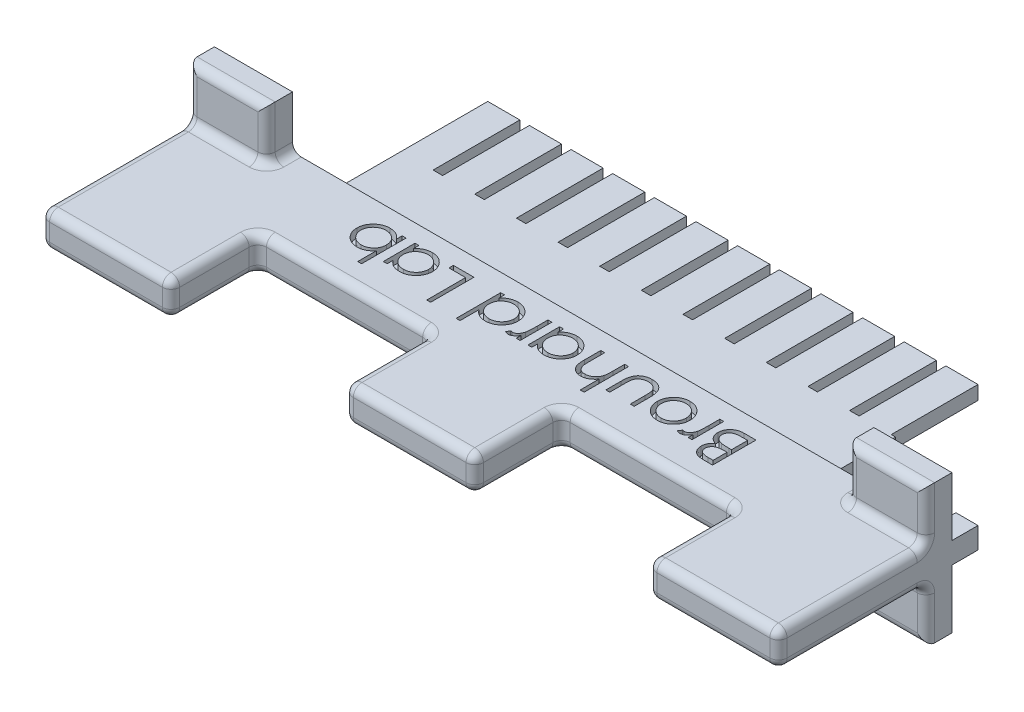
from build123d import *

# Parameters (mm, degrees)
SKETCH1_W           = 85
SKETCH1_H           = 4
BOSS_EXTRUDE1_DEPTH = 10
SKETCH2_W           = 15
SKETCH2_H           = 4
BOSS_EXTRUDE2_DEPTH = 10
SKETCH3_W           = 2.55
SKETCH3_H           = 2.45
BOSS_EXTRUDE3_DEPTH = 3
SKETCH4_W           = 57
SKETCH4_H           = 1.6
BOSS_EXTRUDE4_DEPTH = 7.5
SKETCH6_W           = 9
SKETCH6_H           = 6
BOSS_EXTRUDE6_DEPTH = 3
FILLET1_R           = 1
CUT_EXTRUDE1_DEPTH  = 1
SKETCH5_W           = 3.7
SKETCH5_H           = 1.6
BOSS_EXTRUDE5_DEPTH = 10


with BuildPart() as part:
    # Sketch1 → Boss-Extrude1 (new body)
    with BuildSketch(Plane.XY):
        Rectangle(SKETCH1_W, SKETCH1_H)
    extrude(amount=BOSS_EXTRUDE1_DEPTH)

    # Sketch2 → Boss-Extrude2 (add)
    with BuildSketch(Plane.XY.offset(10)):
        with Locations((-35, 0)):
            Rectangle(SKETCH2_W, SKETCH2_H)
        with Locations((35, 0)):
            Rectangle(SKETCH2_W, SKETCH2_H)
        Rectangle(SKETCH2_W, SKETCH2_H)
    extrude(amount=BOSS_EXTRUDE2_DEPTH)

    # Sketch3 → Boss-Extrude3 (add)
    with BuildSketch(Plane(origin=(0, 0, 0), x_dir=(-1, 0, 0), z_dir=(0, 0, -1))):
        with Locations((-41.225, 0)):
            Rectangle(SKETCH3_W, SKETCH3_H)
        with Locations((41.225, 0)):
            Rectangle(SKETCH3_W, SKETCH3_H)
    extrude(amount=BOSS_EXTRUDE3_DEPTH)

    # Sketch4 → Boss-Extrude4 (add)
    with BuildSketch(Plane(origin=(0, 0, 0), x_dir=(-1, 0, 0), z_dir=(0, 0, -1))):
        Rectangle(SKETCH4_W, SKETCH4_H)
    extrude(amount=BOSS_EXTRUDE4_DEPTH)

    # Sketch6 → Boss-Extrude6 (add)
    with BuildSketch(Plane(origin=(0, 0, 0), x_dir=(-1, 0, 0), z_dir=(0, 0, -1))):
        with Locations((38, -5)):
            Rectangle(SKETCH6_W, SKETCH6_H)
        with Locations((38, 5)):
            Rectangle(SKETCH6_W, SKETCH6_H)
        with Locations((-38, -5)):
            Rectangle(SKETCH6_W, SKETCH6_H)
        with Locations((-38, 5)):
            Rectangle(SKETCH6_W, SKETCH6_H)
    extrude(amount=-BOSS_EXTRUDE6_DEPTH)

    # Fillet1
    fillet1_edges = [part.edges().sort_by_distance(p)[0] for p in [
        (-42.5, 5, 3),
        (-38, 2, 3),
        (-33.5, 5, 3),
        (-33.5, 2, 1.5),
        (-38, 8, 3),
        (42.5, -5, 3),
        (38, -2, 3),
        (33.5, -5, 3),
        (33.5, -2, 1.5),
        (38, -8, 3),
        (42.5, 5, 3),
        (38, 8, 3),
        (33.5, 5, 3),
        (38, 2, 3),
        (33.5, 2, 1.5),
        (-17.5, -2, 10),
        (-27.5, 0, 10),
        (-27.5, -2, 15),
        (-27.5, 2, 15),
        (-42.5, 0, 20),
        (-35, -2, 20),
        (-27.5, 0, 20),
        (-35, 2, 20),
        (17.5, 2, 10),
        (27.5, 0, 10),
        (27.5, 2, 15),
        (27.5, -2, 15),
        (42.5, 0, 20),
        (35, 2, 20),
        (27.5, 0, 20),
        (35, -2, 20),
        (17.5, -2, 10),
        (-17.5, 2, 10),
        (7.5, 0, 10),
        (7.5, -2, 15),
        (7.5, 2, 15),
        (-7.5, 0, 10),
        (-7.5, 2, 15),
        (-7.5, -2, 15),
        (7.5, 0, 20),
        (0, 2, 20),
        (-7.5, 0, 20),
        (0, -2, 20),
        (42.5, -2, 11.5),
        (-42.5, -2, 11.5),
        (-42.5, 2, 11.5),
        (42.5, 2, 11.5),
        (-42.5, -5, 3),
        (-38, -8, 3),
        (-33.5, -5, 3),
        (-38, -2, 3),
        (-33.5, -2, 1.5),
    ]]
    fillet(fillet1_edges, radius=FILLET1_R)

    # Sketch8 → Cut-Extrude1 (cut)
    with BuildSketch(Plane(origin=(0, 2, 0), x_dir=(1, 0, 0), z_dir=(0, 1, 0))):
        with BuildLine():
            Line((21.955128205, -7.045024133), (20.979567308, -7.045024133))
            add(Edge.make_bspline(
                [(20.979567308, -7.045024133), (20.931811586, -7.044777014), (20.839249111, -7.044298035), (20.704660144, -7.036696988), (20.578554958, -7.026592114), (20.461156398, -7.009641733), (20.351700568, -6.992066423), (20.251298675, -6.966270076), (20.159109728, -6.937777071), (20.048409672, -6.893936716), (19.92280529, -6.825852091), (19.787804083, -6.724876123), (19.670452795, -6.603814091), (19.570669416, -6.465854357), (19.490591132, -6.314083016), (19.43339094, -6.151765477), (19.396643358, -5.981632539), (19.392911608, -5.864990679), (19.391025641, -5.806041761)],
                knots=[0, 0, 0, 0, 0.000143243, 0.000277641, 0.000404323, 0.000522601, 0.000633422, 0.000736665, 0.000833282, 0.000922745, 0.001093491, 0.001260157, 0.001426607, 0.001597303, 0.001769346, 0.001939468, 0.002112331, 0.002288957, 0.002288957, 0.002288957, 0.002288957], degree=3))
            add(Edge.make_bspline(
                [(19.391025641, -5.806041761), (19.392566125, -5.750816773), (19.395593321, -5.642294463), (19.425166581, -5.484100137), (19.4698067, -5.333038737), (19.534225102, -5.190566035), (19.616363978, -5.057933935), (19.716298264, -4.937404803), (19.834792937, -4.831345021), (19.923759393, -4.772321243), (19.968950321, -4.742339838)],
                knots=[0, 0, 0, 0, 0.00016551, 0.000325243, 0.000481139, 0.000637145, 0.000792791, 0.000947835, 0.001105294, 0.001267844, 0.001267844, 0.001267844, 0.001267844], degree=3))
            add(Edge.make_bspline(
                [(19.968950321, -4.742339838), (19.912145679, -4.720542475), (19.803464327, -4.678838718), (19.653711211, -4.604821394), (19.524645211, -4.524933301), (19.41460302, -4.438588883), (19.32239544, -4.34296875), (19.240253224, -4.240591123), (19.170541651, -4.127890536), (19.111062126, -4.007309158), (19.063944891, -3.879485542), (19.031238978, -3.745375962), (19.010496783, -3.606499394), (19.007784363, -3.512111636), (19.006410256, -3.464294967)],
                knots=[0, 0, 0, 0, 0.000182459, 0.00034909, 0.000500276, 0.000637148, 0.000767471, 0.00089793, 0.001030217, 0.001164151, 0.001300726, 0.001437979, 0.001577644, 0.001721044, 0.001721044, 0.001721044, 0.001721044], degree=3))
            add(Edge.make_bspline(
                [(19.006410256, -3.464294967), (19.007805885, -3.41548523), (19.010551822, -3.319450707), (19.030807012, -3.178370784), (19.065112767, -3.043553694), (19.112331393, -2.914102037), (19.173883248, -2.790773975), (19.248244287, -2.672600284), (19.337493216, -2.561332318), (19.437996289, -2.45535544), (19.550128803, -2.358444164), (19.673690061, -2.2751618), (19.805513315, -2.203227398), (19.947403728, -2.145396174), (20.098354491, -2.100124903), (20.258400966, -2.068824422), (20.427452272, -2.047649449), (20.543467886, -2.045914087), (20.602964744, -2.045024133)],
                knots=[0, 0, 0, 0, 0.000146402, 0.00028805, 0.000426518, 0.000563092, 0.000700608, 0.000839267, 0.000981145, 0.001127794, 0.001276955, 0.001424748, 0.00157399, 0.001726698, 0.001883553, 0.002046002, 0.002215459, 0.002393845, 0.002393845, 0.002393845, 0.002393845], degree=3))
            Line((20.602964744, -2.045024133), (21.955128205, -2.045024133))
            Line((21.955128205, -2.045024133), (21.955128205, -7.045024133))
        make_face()
        with BuildLine():
            Line((21.506410256, -6.53220362), (21.506410256, -4.929639518))
            Line((21.506410256, -4.929639518), (21.204927885, -4.929639518))
            add(Edge.make_bspline(
                [(21.204927885, -4.929639518), (21.16085778, -4.930206082), (21.075705357, -4.9313008), (20.952063514, -4.934535484), (20.837581625, -4.943196106), (20.731865233, -4.952356158), (20.635622811, -4.966460704), (20.548532434, -4.983720889), (20.469810894, -5.00181496), (20.379071632, -5.032675643), (20.276157749, -5.077807077), (20.16721677, -5.149562501), (20.069164992, -5.232639769), (19.988277934, -5.331182392), (19.920936523, -5.437599512), (19.875598165, -5.552684686), (19.843986577, -5.672472047), (19.841172407, -5.755083607), (19.83974359, -5.797027338)],
                knots=[0, 0, 0, 0, 0.000132227, 0.000255489, 0.000370952, 0.000476596, 0.000573767, 0.000662554, 0.000742964, 0.000815812, 0.000949851, 0.001078759, 0.001205868, 0.001333854, 0.001459773, 0.001581973, 0.001703679, 0.001829203, 0.001829203, 0.001829203, 0.001829203], degree=3))
            add(Edge.make_bspline(
                [(19.83974359, -5.797027338), (19.840440447, -5.824795004), (19.841807408, -5.879264312), (19.85469429, -5.958622966), (19.872478035, -6.034141042), (19.901807859, -6.103782707), (19.936556119, -6.169993364), (19.98109509, -6.230681546), (20.03245262, -6.287491301), (20.092329064, -6.338899898), (20.160479658, -6.385396007), (20.239063252, -6.424101797), (20.325943351, -6.458499162), (20.422931675, -6.48457317), (20.528096305, -6.507209559), (20.643041681, -6.521483941), (20.767075062, -6.530654029), (20.853013063, -6.531675569), (20.897435897, -6.53220362)],
                knots=[0, 0, 0, 0, 8.3229e-05, 0.000163264, 0.000240757, 0.000315341, 0.000389283, 0.000464617, 0.000540481, 0.000618594, 0.000700823, 0.000787274, 0.000880832, 0.000980716, 0.001088168, 0.001203335, 0.00132786, 0.001461107, 0.001461107, 0.001461107, 0.001461107], degree=3))
            Line((20.897435897, -6.53220362), (21.506410256, -6.53220362))
        make_face(mode=Mode.SUBTRACT)
        with BuildLine():
            Line((21.506410256, -4.416819005), (21.506410256, -2.557844646))
            Line((21.506410256, -2.557844646), (20.867387821, -2.557844646))
            add(Edge.make_bspline(
                [(20.867387821, -2.557844646), (20.82165107, -2.558445571), (20.733499514, -2.559603775), (20.606126985, -2.562352033), (20.48869926, -2.57254806), (20.380238634, -2.582323383), (20.281246941, -2.598293401), (20.190761319, -2.61375789), (20.110848501, -2.63651465), (20.017345889, -2.667828353), (19.912764158, -2.717871803), (19.798555972, -2.791464981), (19.697962318, -2.881106895), (19.612615651, -2.984324471), (19.541653639, -3.095395221), (19.492561941, -3.214537751), (19.460753316, -3.337772506), (19.457007017, -3.422035912), (19.455128205, -3.464294967)],
                knots=[0, 0, 0, 0, 0.000137234, 0.000264501, 0.000382034, 0.000490767, 0.000591058, 0.000682796, 0.000765899, 0.000840017, 0.000978463, 0.001112367, 0.001246451, 0.001380849, 0.001513136, 0.001640186, 0.001766022, 0.001892621, 0.001892621, 0.001892621, 0.001892621], degree=3))
            add(Edge.make_bspline(
                [(19.455128205, -3.464294967), (19.455511728, -3.490717987), (19.456272588, -3.543137822), (19.468232548, -3.620102651), (19.484829912, -3.695025725), (19.509289766, -3.766889341), (19.538879538, -3.836930979), (19.577915987, -3.902871611), (19.621948812, -3.967518228), (19.690148998, -4.050208407), (19.790699472, -4.144331407), (19.933635519, -4.235332182), (20.095250073, -4.309910154), (20.212743455, -4.341437989), (20.2734375, -4.357724454)],
                knots=[0, 0, 0, 0, 7.9184e-05, 0.00015709, 0.000233139, 0.000309156, 0.000384516, 0.000460796, 0.000538586, 0.000618995, 0.000781989, 0.000949233, 0.001125381, 0.001313608, 0.001313608, 0.001313608, 0.001313608], degree=3))
            add(Edge.make_bspline(
                [(20.2734375, -4.357724454), (20.297764757, -4.36266062), (20.350511268, -4.373363246), (20.436522534, -4.384653585), (20.535045896, -4.394781387), (20.645660247, -4.402076233), (20.768805516, -4.409907124), (20.904442139, -4.412844185), (21.052666008, -4.416429024), (21.15551238, -4.416685686), (21.208934295, -4.416819005)],
                knots=[0, 0, 0, 0, 7.4449e-05, 0.000161422, 0.000260089, 0.000371555, 0.000493951, 0.000630228, 0.000778496, 0.000938755, 0.000938755, 0.000938755, 0.000938755], degree=3))
            Line((21.208934295, -4.416819005), (21.506410256, -4.416819005))
        make_face(mode=Mode.SUBTRACT)
        with BuildLine():
            Line((18.237179487, -5.698870287), (17.788461538, -5.698870287))
            Line((17.788461538, -5.698870287), (17.788461538, -5.16100971))
            add(Edge.make_bspline(
                [(17.788461538, -5.16100971), (17.755359908, -5.211117117), (17.692053298, -5.306947144), (17.586273377, -5.43343718), (17.479111393, -5.53983342), (17.366921794, -5.622588498), (17.252557594, -5.685650706), (17.136357118, -5.730343447), (17.017481778, -5.757585182), (16.937237879, -5.761174556), (16.897035256, -5.762972851)],
                knots=[0, 0, 0, 0, 0.000180032, 0.00034431, 0.000493764, 0.000631989, 0.000761087, 0.000884414, 0.00100446, 0.00112499, 0.00112499, 0.00112499, 0.00112499], degree=3))
            add(Edge.make_bspline(
                [(16.897035256, -5.762972851), (16.865844687, -5.761310147), (16.801992924, -5.757906343), (16.705041331, -5.732794344), (16.604739598, -5.694222955), (16.540012887, -5.657063647), (16.506410256, -5.637772531)],
                knots=[0, 0, 0, 0, 9.3493e-05, 0.000191394, 0.000298902, 0.000414971, 0.000414971, 0.000414971, 0.000414971], degree=3))
            Line((16.506410256, -5.637772531), (16.752804487, -5.249150736))
            add(Edge.make_bspline(
                [(16.752804487, -5.249150736), (16.774388803, -5.258779687), (16.815359967, -5.277057281), (16.875295061, -5.298688724), (16.930554114, -5.311425747), (16.965759197, -5.313355343), (16.982171474, -5.314254902)],
                knots=[0, 0, 0, 0, 7.0888e-05, 0.000134558, 0.000190943, 0.000240184, 0.000240184, 0.000240184, 0.000240184], degree=3))
            add(Edge.make_bspline(
                [(16.982171474, -5.314254902), (17.018552318, -5.311962095), (17.092095887, -5.307327204), (17.199553418, -5.267726819), (17.305221395, -5.20820996), (17.387285817, -5.138004944), (17.451536641, -5.071852679), (17.497773588, -5.013639038), (17.539299542, -4.947803919), (17.579572406, -4.876841023), (17.616991286, -4.798984205), (17.65042989, -4.714102186), (17.681701622, -4.622897124), (17.699312387, -4.559480067), (17.708333333, -4.526995287)],
                knots=[0, 0, 0, 0, 0.000108839, 0.000220017, 0.000339778, 0.000471355, 0.000542193, 0.000616339, 0.000693851, 0.000775474, 0.000861039, 0.000952734, 0.001049023, 0.001150145, 0.001150145, 0.001150145, 0.001150145], degree=3))
            add(Edge.make_bspline(
                [(17.708333333, -4.526995287), (17.715105579, -4.4980295), (17.73018081, -4.433550753), (17.744447085, -4.325868753), (17.75911049, -4.198727857), (17.769124119, -4.051980366), (17.778583328, -3.885062178), (17.783808984, -3.698693379), (17.788295276, -3.492361731), (17.78840435, -3.348446216), (17.788461538, -3.272988877)],
                knots=[0, 0, 0, 0, 8.9193e-05, 0.000198547, 0.000325526, 0.000473173, 0.000639683, 0.000827079, 0.001032447, 0.001258811, 0.001258811, 0.001258811, 0.001258811], degree=3))
            Line((17.788461538, -3.272988877), (17.788461538, -2.045024133))
            Line((17.788461538, -2.045024133), (18.237179487, -2.045024133))
            Line((18.237179487, -2.045024133), (18.237179487, -5.698870287))
        make_face()
        with BuildLine():
            add(Edge.make_bspline(
                [(14.29286859, -5.762972851), (14.224307927, -5.761517291), (14.089877222, -5.758663293), (13.893032913, -5.728009819), (13.705327588, -5.681525783), (13.525956048, -5.616093456), (13.356402056, -5.530243686), (13.195151776, -5.426425769), (13.042528278, -5.303937317), (12.951070622, -5.209132095), (12.904647436, -5.16100971)],
                knots=[0, 0, 0, 0, 0.000205526, 0.000402987, 0.000596112, 0.000784972, 0.000974447, 0.001165038, 0.001359476, 0.001559909, 0.001559909, 0.001559909, 0.001559909], degree=3))
            add(Edge.make_bspline(
                [(12.904647436, -5.16100971), (12.864673216, -5.11498973), (12.785498387, -5.023840384), (12.683975931, -4.876046652), (12.59651656, -4.722989365), (12.526426616, -4.562636041), (12.471162296, -4.396386511), (12.431925587, -4.223669352), (12.408587109, -4.044865999), (12.405440013, -3.923431945), (12.403846154, -3.861931185)],
                knots=[0, 0, 0, 0, 0.000182745, 0.000361954, 0.000536876, 0.000710881, 0.000886036, 0.001061708, 0.001241475, 0.001425944, 0.001425944, 0.001425944, 0.001425944], degree=3))
            add(Edge.make_bspline(
                [(12.403846154, -3.861931185), (12.405248064, -3.800073959), (12.408018305, -3.677841197), (12.434223472, -3.497813533), (12.474982163, -3.323249495), (12.533313369, -3.154879952), (12.608110636, -2.992190127), (12.699383171, -2.835891045), (12.807770716, -2.685672654), (12.930635425, -2.542816985), (13.066416897, -2.411135675), (13.21375075, -2.296436369), (13.369848434, -2.197755629), (13.536840837, -2.119375683), (13.712350874, -2.056195988), (13.8974949, -2.012629522), (14.09210775, -1.986052796), (14.225006973, -1.982656037), (14.29286859, -1.980921569)],
                knots=[0, 0, 0, 0, 0.00018547, 0.000366497, 0.000544574, 0.000722589, 0.000900065, 0.001080956, 0.001264689, 0.001455025, 0.001645575, 0.001831106, 0.002014249, 0.002198383, 0.002383395, 0.002572886, 0.002767942, 0.002971467, 0.002971467, 0.002971467, 0.002971467], degree=3))
            add(Edge.make_bspline(
                [(14.29286859, -1.980921569), (14.361059424, -1.982670388), (14.494614618, -1.986095539), (14.689960267, -2.012431829), (14.875883807, -2.056661478), (15.052224048, -2.118593533), (15.219215773, -2.198399418), (15.37588985, -2.296052412), (15.523293198, -2.411193757), (15.65911724, -2.542801247), (15.781970535, -2.685676709), (15.890361026, -2.835889993), (15.981632796, -2.992190401), (16.056430263, -3.154879879), (16.114761415, -3.323249515), (16.155520121, -3.497813528), (16.181725284, -3.677841198), (16.184495525, -3.80007396), (16.185897436, -3.861931185)],
                knots=[0, 0, 0, 0, 0.000204526, 0.000400574, 0.000590065, 0.000776965, 0.000960195, 0.001144188, 0.00132972, 0.001520269, 0.001710605, 0.001894339, 0.00207523, 0.002252706, 0.002430721, 0.002608798, 0.002789825, 0.002975294, 0.002975294, 0.002975294, 0.002975294], degree=3))
            add(Edge.make_bspline(
                [(16.185897436, -3.861931185), (16.184296519, -3.923099043), (16.18112698, -4.044200892), (16.157756652, -4.22264832), (16.118946868, -4.394836864), (16.062916427, -4.560178538), (15.992956591, -4.720146456), (15.90637746, -4.873764934), (15.803872945, -5.02091287), (15.725005709, -5.111941341), (15.685096154, -5.158004902)],
                knots=[0, 0, 0, 0, 0.000183468, 0.000363236, 0.000538908, 0.000712162, 0.000886167, 0.001061962, 0.001240348, 0.001423094, 0.001423094, 0.001423094, 0.001423094], degree=3))
            add(Edge.make_bspline(
                [(15.685096154, -5.158004902), (15.638739114, -5.20653651), (15.547569839, -5.301982456), (15.394241809, -5.424229232), (15.233685171, -5.529446865), (15.063037498, -5.615253429), (14.883167202, -5.681407061), (14.694066814, -5.728226774), (14.496506031, -5.758527704), (14.361424213, -5.761476369), (14.29286859, -5.762972851)],
                knots=[0, 0, 0, 0, 0.00020114, 0.000395577, 0.000586713, 0.000776188, 0.000967274, 0.001160399, 0.001359841, 0.001565367, 0.001565367, 0.001565367, 0.001565367], degree=3))
        make_face()
        with BuildLine():
            add(Edge.make_bspline(
                [(14.294871795, -5.314254902), (14.343354042, -5.31287684), (14.439066976, -5.310156289), (14.579952881, -5.289466071), (14.715578773, -5.256679949), (14.84621924, -5.210117374), (14.971369132, -5.149920796), (15.091165691, -5.076401027), (15.205288814, -4.989167289), (15.312855022, -4.88995037), (15.412753003, -4.782192755), (15.499001382, -4.666286529), (15.572889716, -4.545452386), (15.633262525, -4.419007361), (15.679580189, -4.286604065), (15.712397714, -4.149000046), (15.733127199, -4.005785755), (15.735814091, -3.908409845), (15.737179487, -3.858926377)],
                knots=[0, 0, 0, 0, 0.000145402, 0.00028705, 0.000426247, 0.000563423, 0.000702299, 0.000842129, 0.000984361, 0.00113252, 0.001280679, 0.00142451, 0.001565195, 0.001704975, 0.001844039, 0.001985183, 0.002128814, 0.002277217, 0.002277217, 0.002277217, 0.002277217], degree=3))
            add(Edge.make_bspline(
                [(15.737179487, -3.858926377), (15.734890082, -3.794992084), (15.730346041, -3.668094469), (15.693206633, -3.48126298), (15.631516344, -3.301562306), (15.546449569, -3.131156088), (15.441687276, -2.973216762), (15.31918926, -2.831196974), (15.177261944, -2.710573578), (15.020738225, -2.609127271), (14.851836243, -2.5292384), (14.673387712, -2.471947456), (14.487017459, -2.435206285), (14.359480893, -2.431511347), (14.294871795, -2.429639518)],
                knots=[0, 0, 0, 0, 0.000191683, 0.000380455, 0.000568919, 0.000760186, 0.000950198, 0.001136194, 0.00132088, 0.001507019, 0.001694298, 0.001879594, 0.002068178, 0.002261801, 0.002261801, 0.002261801, 0.002261801], degree=3))
            add(Edge.make_bspline(
                [(14.294871795, -2.429639518), (14.23025898, -2.431500504), (14.102715078, -2.435174039), (13.916085515, -2.472133599), (13.737147914, -2.528989279), (13.568070317, -2.609217501), (13.411475317, -2.710190138), (13.270561459, -2.831884154), (13.147008507, -2.972843418), (13.04214248, -3.130946672), (12.958446366, -3.301827223), (12.896465966, -3.481229869), (12.859415628, -3.668102902), (12.854859565, -3.794994909), (12.852564103, -3.858926377)],
                knots=[0, 0, 0, 0, 0.000193623, 0.000382206, 0.000568456, 0.000755734, 0.000941873, 0.001125801, 0.001312456, 0.001502468, 0.001693291, 0.001881755, 0.002070527, 0.00226221, 0.00226221, 0.00226221, 0.00226221], degree=3))
            add(Edge.make_bspline(
                [(12.852564103, -3.858926377), (12.85391927, -3.908413822), (12.856586033, -4.00579756), (12.877461924, -4.148954918), (12.909764333, -4.286878115), (12.958078967, -4.418473367), (13.016348399, -4.546067931), (13.092028067, -4.665924648), (13.177874936, -4.782266279), (13.277956043, -4.889885455), (13.385510177, -4.98952979), (13.500490643, -5.076083255), (13.620342842, -5.149962779), (13.745532283, -5.210124787), (13.875877117, -5.256500729), (14.011091241, -5.289608892), (14.151353237, -5.310080851), (14.246726302, -5.312854653), (14.294871795, -5.314254902)],
                knots=[0, 0, 0, 0, 0.000148403, 0.000292034, 0.000433178, 0.000572578, 0.00071193, 0.000853138, 0.000996969, 0.001145128, 0.001293287, 0.001436317, 0.001576147, 0.001715023, 0.001852199, 0.001990424, 0.002132072, 0.002276473, 0.002276473, 0.002276473, 0.002276473], degree=3))
        make_face(mode=Mode.SUBTRACT)
        with BuildLine():
            Line((11.570512821, -5.698870287), (11.121794872, -5.698870287))
            Line((11.121794872, -5.698870287), (11.121794872, -4.004158749))
            add(Edge.make_bspline(
                [(11.121794872, -4.004158749), (11.121592151, -3.954411964), (11.121204354, -3.859248695), (11.118574439, -3.722312714), (11.112388591, -3.597431696), (11.104654555, -3.484533501), (11.094708647, -3.383637227), (11.082875275, -3.295095289), (11.069648958, -3.217903597), (11.056702224, -3.171413089), (11.05068109, -3.149791761)],
                knots=[0, 0, 0, 0, 0.000149242, 0.000285493, 0.000410838, 0.000524302, 0.000624962, 0.000714911, 0.000792314, 0.000859608, 0.000859608, 0.000859608, 0.000859608], degree=3))
            add(Edge.make_bspline(
                [(11.05068109, -3.149791761), (11.041021805, -3.122616307), (11.02190405, -3.06883037), (10.987228565, -2.991130691), (10.944327515, -2.919170094), (10.897397624, -2.850149082), (10.843207537, -2.786203671), (10.78254961, -2.72691621), (10.716500508, -2.671595092), (10.619751651, -2.6048734), (10.487494763, -2.534263345), (10.314242396, -2.472488378), (10.126045943, -2.436112097), (9.995820794, -2.431836921), (9.928886218, -2.429639518)],
                knots=[0, 0, 0, 0, 8.6516e-05, 0.000171232, 0.000254721, 0.000337515, 0.000421387, 0.00050567, 0.000591721, 0.00067952, 0.000857864, 0.001039709, 0.001229465, 0.001430146, 0.001430146, 0.001430146, 0.001430146], degree=3))
            add(Edge.make_bspline(
                [(9.928886218, -2.429639518), (9.86194316, -2.431828713), (9.732748927, -2.436053669), (9.546518851, -2.471939165), (9.375968682, -2.530483395), (9.223089747, -2.613350563), (9.088841758, -2.714376404), (8.976981124, -2.832969142), (8.884684323, -2.965323174), (8.844385248, -3.064072442), (8.82411859, -3.113734069)],
                knots=[0, 0, 0, 0, 0.000200681, 0.000387296, 0.000566586, 0.000739571, 0.000906841, 0.001068376, 0.001227003, 0.001387484, 0.001387484, 0.001387484, 0.001387484], degree=3))
            add(Edge.make_bspline(
                [(8.82411859, -3.113734069), (8.8181224, -3.1336855), (8.80486629, -3.177793242), (8.790725551, -3.252630176), (8.777460105, -3.341789135), (8.768616165, -3.446206446), (8.758522511, -3.564961319), (8.755037146, -3.698667884), (8.750059864, -3.846538026), (8.750020544, -3.950065981), (8.75, -4.004158749)],
                knots=[0, 0, 0, 0, 6.2462e-05, 0.000138088, 0.000228176, 0.000332823, 0.000452355, 0.000585662, 0.000733953, 0.000896216, 0.000896216, 0.000896216, 0.000896216], degree=3))
            Line((8.75, -4.004158749), (8.75, -5.698870287))
            Line((8.75, -5.698870287), (8.301282051, -5.698870287))
            Line((8.301282051, -5.698870287), (8.301282051, -3.920024133))
            add(Edge.make_bspline(
                [(8.301282051, -3.920024133), (8.30191531, -3.859585653), (8.303143917, -3.742326733), (8.310980731, -3.571916291), (8.324614367, -3.412799073), (8.344773775, -3.265462167), (8.369229918, -3.129870336), (8.400154934, -3.00598092), (8.437277048, -2.893621613), (8.479165629, -2.791153018), (8.528529202, -2.698158121), (8.581390514, -2.610389295), (8.640827886, -2.528135886), (8.705652894, -2.450645369), (8.777741804, -2.379798189), (8.85333008, -2.311961845), (8.93610888, -2.251321381), (9.023288539, -2.194646502), (9.117066908, -2.144351467), (9.216637391, -2.100832577), (9.321894658, -2.063022013), (9.433003103, -2.033803946), (9.549897573, -2.009153726), (9.67242881, -1.992746928), (9.800829998, -1.982271357), (9.888132562, -1.981379054), (9.932892628, -1.980921569)],
                knots=[0, 0, 0, 0, 0.000181315, 0.000351776, 0.000511647, 0.000660239, 0.000797754, 0.000924804, 0.001042946, 0.001152506, 0.001256441, 0.001358477, 0.001459659, 0.001560587, 0.001661157, 0.001762636, 0.001865001, 0.001968632, 0.00207439, 0.002183817, 0.002294379, 0.002409546, 0.002528193, 0.002652561, 0.002780158, 0.002914407, 0.002914407, 0.002914407, 0.002914407], degree=3))
            add(Edge.make_bspline(
                [(9.932892628, -1.980921569), (9.977316456, -1.981406186), (10.064613414, -1.982358504), (10.192711845, -1.992570693), (10.315507575, -2.00940504), (10.432494069, -2.033606354), (10.544142851, -2.063257518), (10.649911875, -2.100566743), (10.749934706, -2.144600485), (10.84442655, -2.194693497), (10.933073912, -2.251115088), (11.015677547, -2.313213364), (11.093710062, -2.379368112), (11.165005381, -2.451835522), (11.23008642, -2.530073038), (11.28923533, -2.613729086), (11.343463789, -2.701858176), (11.392537938, -2.79623559), (11.434697953, -2.899909467), (11.471919623, -3.014619732), (11.502363426, -3.141623289), (11.527138371, -3.28081177), (11.547069003, -3.431518969), (11.560906348, -3.594616706), (11.568643249, -3.769707694), (11.569876194, -3.890636109), (11.570512821, -3.953077018)],
                knots=[0, 0, 0, 0, 0.000133247, 0.000261843, 0.000385219, 0.000504847, 0.000620013, 0.00073152, 0.000840947, 0.000947589, 0.001052063, 0.001155829, 0.001257407, 0.001358687, 0.001460383, 0.00156238, 0.001665793, 0.001770617, 0.001881102, 0.002001148, 0.002132087, 0.002272558, 0.00242512, 0.002587985, 0.002763448, 0.002950772, 0.002950772, 0.002950772, 0.002950772], degree=3))
            Line((11.570512821, -3.953077018), (11.570512821, -5.698870287))
        make_face()
        with BuildLine():
            Line((7.275641026, -7.173229261), (6.826923077, -7.173229261))
            Line((6.826923077, -7.173229261), (6.826923077, -5.00876612))
            add(Edge.make_bspline(
                [(6.826923077, -5.00876612), (6.778678808, -5.068888094), (6.684893793, -5.185762911), (6.528113976, -5.339904506), (6.36474826, -5.471196487), (6.193410264, -5.578408978), (6.014828183, -5.661579829), (5.828563194, -5.719766634), (5.635090167, -5.756050633), (5.503296595, -5.760649137), (5.436698718, -5.762972851)],
                knots=[0, 0, 0, 0, 0.000231093, 0.000449235, 0.000658061, 0.000858722, 0.001054107, 0.001247341, 0.001442817, 0.001642498, 0.001642498, 0.001642498, 0.001642498], degree=3))
            add(Edge.make_bspline(
                [(5.436698718, -5.762972851), (5.369051259, -5.760620551), (5.236582495, -5.756014225), (5.044402774, -5.715426657), (4.863656734, -5.651196128), (4.696758785, -5.560924861), (4.546286047, -5.448841659), (4.415775284, -5.31738737), (4.306291209, -5.168293369), (4.233038251, -5.029320354), (4.185028125, -4.905733149), (4.154679673, -4.799671692), (4.128934509, -4.68150037), (4.106507375, -4.551264166), (4.091559078, -4.408342759), (4.079552578, -4.253379458), (4.071014758, -4.086383599), (4.070683898, -3.970783239), (4.070512821, -3.91100971)],
                knots=[0, 0, 0, 0, 0.000202742, 0.000397014, 0.000586474, 0.000776485, 0.000963986, 0.001147421, 0.001330122, 0.001516953, 0.001616837, 0.001727454, 0.0018475, 0.00197956, 0.002123683, 0.002278397, 0.002445857, 0.002625155, 0.002625155, 0.002625155, 0.002625155], degree=3))
            Line((4.070512821, -3.91100971), (4.070512821, -2.045024133))
            Line((4.070512821, -2.045024133), (4.519230769, -2.045024133))
            Line((4.519230769, -2.045024133), (4.519230769, -3.763774133))
            add(Edge.make_bspline(
                [(4.519230769, -3.763774133), (4.519501544, -3.813520868), (4.52001949, -3.908677905), (4.521752659, -4.044914373), (4.525533642, -4.16814974), (4.531869413, -4.278639822), (4.53824468, -4.376234881), (4.547283145, -4.46109433), (4.557720701, -4.532685817), (4.567105279, -4.575778103), (4.571314103, -4.595104261)],
                knots=[0, 0, 0, 0, 0.000149242, 0.000285475, 0.000408737, 0.000519077, 0.000617484, 0.0007021, 0.000775053, 0.000834376, 0.000834376, 0.000834376, 0.000834376], degree=3))
            add(Edge.make_bspline(
                [(4.571314103, -4.595104261), (4.587558684, -4.651851981), (4.618706291, -4.760660919), (4.692549434, -4.908198617), (4.782632802, -5.035130852), (4.894290172, -5.137852366), (5.023812243, -5.21879062), (5.172428658, -5.273933897), (5.338240367, -5.309099366), (5.454866892, -5.312485195), (5.515825321, -5.314254902)],
                knots=[0, 0, 0, 0, 0.000176748, 0.000338899, 0.000492364, 0.000641202, 0.000791008, 0.00094763, 0.001114405, 0.001297029, 0.001297029, 0.001297029, 0.001297029], degree=3))
            add(Edge.make_bspline(
                [(5.515825321, -5.314254902), (5.551925349, -5.313584935), (5.623366372, -5.312259087), (5.729246241, -5.298610846), (5.8322736, -5.277055291), (5.932171925, -5.245215815), (6.029144995, -5.206505033), (6.123586995, -5.15899916), (6.21420543, -5.101559446), (6.302169918, -5.036911618), (6.384056208, -4.965394032), (6.460236741, -4.889895628), (6.528148933, -4.809503542), (6.589675418, -4.725503187), (6.642787274, -4.636743532), (6.689148815, -4.544080206), (6.728485525, -4.44739143), (6.748032228, -4.380284199), (6.7578125, -4.346706826)],
                knots=[0, 0, 0, 0, 0.000108247, 0.000214218, 0.000319711, 0.000423617, 0.000528331, 0.0006327, 0.00074025, 0.000849828, 0.000959881, 0.001066117, 0.001171281, 0.001275259, 0.001378152, 0.001481176, 0.00158589, 0.001690753, 0.001690753, 0.001690753, 0.001690753], degree=3))
            add(Edge.make_bspline(
                [(6.7578125, -4.346706826), (6.763440253, -4.322391181), (6.77570382, -4.2694044), (6.789010725, -4.182012509), (6.800921863, -4.080460549), (6.81099122, -3.964902548), (6.817167057, -3.834915059), (6.823821687, -3.691385118), (6.82629885, -3.533413659), (6.826708783, -3.423562934), (6.826923077, -3.366137915)],
                knots=[0, 0, 0, 0, 7.4853e-05, 0.000163113, 0.000264986, 0.000381603, 0.000511, 0.000655356, 0.000812636, 0.000984915, 0.000984915, 0.000984915, 0.000984915], degree=3))
            Line((6.826923077, -3.366137915), (6.826923077, -2.045024133))
            Line((6.826923077, -2.045024133), (7.275641026, -2.045024133))
            Line((7.275641026, -2.045024133), (7.275641026, -7.173229261))
        make_face()
        with BuildLine():
            Line((-0.673076923, -5.698870287), (-0.673076923, -2.045024133))
            Line((-0.673076923, -2.045024133), (-0.224358974, -2.045024133))
            Line((-0.224358974, -2.045024133), (-0.224358974, -2.677035351))
            add(Edge.make_bspline(
                [(-0.224358974, -2.677035351), (-0.173692153, -2.619914798), (-0.074668173, -2.508277549), (0.089136249, -2.361533046), (0.264203306, -2.241723382), (0.447550404, -2.144473643), (0.640596711, -2.07116495), (0.842208477, -2.019519884), (1.052227954, -1.985924035), (1.195449856, -1.982604018), (1.268028846, -1.980921569)],
                knots=[0, 0, 0, 0, 0.000228947, 0.000447457, 0.00065777, 0.000863866, 0.001068669, 0.001275649, 0.001487424, 0.001705002, 0.001705002, 0.001705002, 0.001705002], degree=3))
            add(Edge.make_bspline(
                [(1.268028846, -1.980921569), (1.33255467, -1.982673239), (1.459802451, -1.986127609), (1.646984326, -2.01293508), (1.827125421, -2.055963389), (2.000340544, -2.115878617), (2.16545602, -2.194944018), (2.323402232, -2.290624075), (2.474547798, -2.403447762), (2.616018245, -2.532931528), (2.746457503, -2.673420564), (2.860578679, -2.823701191), (2.957300092, -2.98170931), (3.03678777, -3.14740051), (3.098299504, -3.320653672), (3.141095026, -3.50134994), (3.16787361, -3.689188645), (3.17132623, -3.817102795), (3.173076923, -3.881963236)],
                knots=[0, 0, 0, 0, 0.000193519, 0.000381629, 0.000566016, 0.000748473, 0.000930368, 0.001114167, 0.001301667, 0.001495236, 0.001688742, 0.001876044, 0.002060364, 0.002243594, 0.002426383, 0.002610771, 0.002799872, 0.002994392, 0.002994392, 0.002994392, 0.002994392], degree=3))
            add(Edge.make_bspline(
                [(3.173076923, -3.881963236), (3.1712874, -3.945483083), (3.167749609, -4.071058395), (3.141381566, -4.255738336), (3.097074815, -4.43363601), (3.034777431, -4.604092418), (2.955247483, -4.767794043), (2.856862681, -4.923460082), (2.742782629, -5.073471787), (2.610949305, -5.213018547), (2.468209109, -5.341451795), (2.316217898, -5.454549666), (2.156870853, -5.549984408), (1.989848458, -5.627563574), (1.81633338, -5.689212702), (1.635007518, -5.732188081), (1.446695469, -5.757450724), (1.318853253, -5.761114455), (1.25400641, -5.762972851)],
                knots=[0, 0, 0, 0, 0.000190518, 0.000376644, 0.000558351, 0.000739594, 0.000920119, 0.001103261, 0.001291171, 0.001484625, 0.001678266, 0.00186657, 0.002052086, 0.00223446, 0.002418194, 0.002603555, 0.002792521, 0.002987041, 0.002987041, 0.002987041, 0.002987041], degree=3))
            add(Edge.make_bspline(
                [(1.25400641, -5.762972851), (1.179433695, -5.760926632), (1.03320012, -5.756914093), (0.81900525, -5.723236763), (0.616281151, -5.666868078), (0.423271915, -5.589930632), (0.242689948, -5.486323272), (0.072799241, -5.358126181), (-0.084384391, -5.202231444), (-0.176893656, -5.083637559), (-0.224358974, -5.022788556)],
                knots=[0, 0, 0, 0, 0.000223629, 0.000438526, 0.00064848, 0.000853819, 0.001060171, 0.00127111, 0.001490669, 0.00172203, 0.00172203, 0.00172203, 0.00172203], degree=3))
            Line((-0.224358974, -5.022788556), (-0.224358974, -5.698870287))
            Line((-0.224358974, -5.698870287), (-0.673076923, -5.698870287))
        make_face()
        with BuildLine():
            add(Edge.make_bspline(
                [(1.247996795, -5.314254902), (1.313587334, -5.311919162), (1.443052626, -5.307308782), (1.633135329, -5.271375167), (1.81493707, -5.211432861), (1.988162207, -5.129927244), (2.148028307, -5.025521063), (2.293274093, -4.90241808), (2.4199622, -4.759110049), (2.527080559, -4.598889493), (2.61600865, -4.428155027), (2.677375939, -4.248376808), (2.71813637, -4.064413876), (2.722279372, -3.93960414), (2.724358974, -3.876955223)],
                knots=[0, 0, 0, 0, 0.000196682, 0.000388218, 0.000577945, 0.000769701, 0.000960837, 0.001149109, 0.001339255, 0.001532603, 0.001726118, 0.001914908, 0.002101131, 0.002288816, 0.002288816, 0.002288816, 0.002288816], degree=3))
            add(Edge.make_bspline(
                [(2.724358974, -3.876955223), (2.721659394, -3.814696014), (2.716270816, -3.690421632), (2.678628159, -3.506176784), (2.612554386, -3.327571475), (2.52557156, -3.154636161), (2.41676702, -2.993220534), (2.290328958, -2.847266396), (2.144346166, -2.722265786), (1.983072348, -2.617564507), (1.811006067, -2.533340742), (1.629993631, -2.473937453), (1.443190032, -2.436430737), (1.315946515, -2.431910872), (1.252003205, -2.429639518)],
                knots=[0, 0, 0, 0, 0.000186753, 0.000372773, 0.00056129, 0.00075659, 0.000952159, 0.001143808, 0.001334144, 0.001526666, 0.001719289, 0.001907113, 0.002096868, 0.002288551, 0.002288551, 0.002288551, 0.002288551], degree=3))
            add(Edge.make_bspline(
                [(1.252003205, -2.429639518), (1.187080663, -2.432002624), (1.058284568, -2.436690656), (0.867544613, -2.472872088), (0.682784064, -2.533558691), (0.505507589, -2.61619592), (0.340640106, -2.718645983), (0.193357608, -2.839118095), (0.066119696, -2.97708118), (-0.038639755, -3.131710873), (-0.122341141, -3.29936144), (-0.181608072, -3.478428524), (-0.217604718, -3.667848043), (-0.222076425, -3.797668511), (-0.224358974, -3.86393439)],
                knots=[0, 0, 0, 0, 0.000194682, 0.000386219, 0.000580065, 0.000776779, 0.000971601, 0.00116089, 0.001345905, 0.001532593, 0.001719381, 0.001906254, 0.002096806, 0.002295487, 0.002295487, 0.002295487, 0.002295487], degree=3))
            add(Edge.make_bspline(
                [(-0.224358974, -3.86393439), (-0.222988015, -3.914416985), (-0.220289533, -4.013782709), (-0.199674743, -4.159679441), (-0.166880858, -4.29929803), (-0.120676169, -4.432791295), (-0.059958997, -4.559398956), (0.013194296, -4.680113441), (0.100284193, -4.793810311), (0.198660327, -4.90034558), (0.307556085, -4.997030357), (0.42335261, -5.082247508), (0.545758559, -5.154364667), (0.674688011, -5.212077257), (0.809147942, -5.259094257), (0.950427125, -5.290148173), (1.097101723, -5.311539529), (1.197168848, -5.313340248), (1.247996795, -5.314254902)],
                knots=[0, 0, 0, 0, 0.000151404, 0.000298012, 0.000441104, 0.000581114, 0.000720894, 0.000861579, 0.00100381, 0.001149818, 0.001295962, 0.001440002, 0.001580519, 0.001721272, 0.001863175, 0.002007015, 0.002154615, 0.002306977, 0.002306977, 0.002306977, 0.002306977], degree=3))
        make_face(mode=Mode.SUBTRACT)
        with BuildLine():
            Line((-1.570512821, -5.698870287), (-2.019230769, -5.698870287))
            Line((-2.019230769, -5.698870287), (-2.019230769, -5.16100971))
            add(Edge.make_bspline(
                [(-2.019230769, -5.16100971), (-2.052332399, -5.211117117), (-2.11563901, -5.306947144), (-2.221418931, -5.43343718), (-2.328580915, -5.53983342), (-2.440770514, -5.622588498), (-2.555134714, -5.685650706), (-2.67133519, -5.730343447), (-2.79021053, -5.757585182), (-2.870454429, -5.761174556), (-2.910657051, -5.762972851)],
                knots=[0, 0, 0, 0, 0.000180032, 0.00034431, 0.000493764, 0.000631989, 0.000761087, 0.000884414, 0.00100446, 0.00112499, 0.00112499, 0.00112499, 0.00112499], degree=3))
            add(Edge.make_bspline(
                [(-2.910657051, -5.762972851), (-2.94184762, -5.761310147), (-3.005699384, -5.757906343), (-3.102650976, -5.732794344), (-3.202952709, -5.694222955), (-3.267679421, -5.657063647), (-3.301282051, -5.637772531)],
                knots=[0, 0, 0, 0, 9.3493e-05, 0.000191394, 0.000298902, 0.000414971, 0.000414971, 0.000414971, 0.000414971], degree=3))
            Line((-3.301282051, -5.637772531), (-3.054887821, -5.249150736))
            add(Edge.make_bspline(
                [(-3.054887821, -5.249150736), (-3.033303505, -5.258779687), (-2.992332341, -5.277057281), (-2.932397246, -5.298688724), (-2.877138194, -5.311425747), (-2.84193311, -5.313355343), (-2.825520833, -5.314254902)],
                knots=[0, 0, 0, 0, 7.0888e-05, 0.000134558, 0.000190943, 0.000240184, 0.000240184, 0.000240184, 0.000240184], degree=3))
            add(Edge.make_bspline(
                [(-2.825520833, -5.314254902), (-2.78913999, -5.311962095), (-2.715596421, -5.307327204), (-2.608138889, -5.267726819), (-2.502470912, -5.20820996), (-2.420406491, -5.138004944), (-2.356155667, -5.071852679), (-2.309918719, -5.013639038), (-2.268392765, -4.947803919), (-2.228119902, -4.876841023), (-2.190701022, -4.798984205), (-2.157262418, -4.714102186), (-2.125990686, -4.622897124), (-2.10837992, -4.559480067), (-2.099358974, -4.526995287)],
                knots=[0, 0, 0, 0, 0.000108839, 0.000220017, 0.000339778, 0.000471355, 0.000542193, 0.000616339, 0.000693851, 0.000775474, 0.000861039, 0.000952734, 0.001049023, 0.001150145, 0.001150145, 0.001150145, 0.001150145], degree=3))
            add(Edge.make_bspline(
                [(-2.099358974, -4.526995287), (-2.092586729, -4.4980295), (-2.077511498, -4.433550753), (-2.063245223, -4.325868753), (-2.048581818, -4.198727857), (-2.038568188, -4.051980366), (-2.02910898, -3.885062178), (-2.023883323, -3.698693379), (-2.019397031, -3.492361731), (-2.019287958, -3.348446216), (-2.019230769, -3.272988877)],
                knots=[0, 0, 0, 0, 8.9193e-05, 0.000198547, 0.000325526, 0.000473173, 0.000639683, 0.000827079, 0.001032447, 0.001258811, 0.001258811, 0.001258811, 0.001258811], degree=3))
            Line((-2.019230769, -3.272988877), (-2.019230769, -2.045024133))
            Line((-2.019230769, -2.045024133), (-1.570512821, -2.045024133))
            Line((-1.570512821, -2.045024133), (-1.570512821, -5.698870287))
        make_face()
        with BuildLine():
            Line((-7.467948718, -7.173229261), (-7.467948718, -2.045024133))
            Line((-7.467948718, -2.045024133), (-7.019230769, -2.045024133))
            Line((-7.019230769, -2.045024133), (-7.019230769, -2.677035351))
            add(Edge.make_bspline(
                [(-7.019230769, -2.677035351), (-6.968563948, -2.619914798), (-6.869539967, -2.508277549), (-6.705735546, -2.361533046), (-6.530668489, -2.241723382), (-6.347321391, -2.144473643), (-6.154275084, -2.07116495), (-5.952663318, -2.019519884), (-5.74264384, -1.985924035), (-5.599421939, -1.982604018), (-5.526842949, -1.980921569)],
                knots=[0, 0, 0, 0, 0.000228947, 0.000447457, 0.00065777, 0.000863866, 0.001068669, 0.001275649, 0.001487424, 0.001705002, 0.001705002, 0.001705002, 0.001705002], degree=3))
            add(Edge.make_bspline(
                [(-5.526842949, -1.980921569), (-5.462317125, -1.982673239), (-5.335069344, -1.986127609), (-5.147887469, -2.01293508), (-4.967746374, -2.055963389), (-4.794531251, -2.115878617), (-4.629415775, -2.194944018), (-4.471469563, -2.290624075), (-4.320323997, -2.403447762), (-4.17885355, -2.532931528), (-4.048414292, -2.673420564), (-3.934293116, -2.823701191), (-3.837571703, -2.98170931), (-3.758084025, -3.14740051), (-3.696572291, -3.320653672), (-3.653776768, -3.50134994), (-3.626998185, -3.689188645), (-3.623545565, -3.817102795), (-3.621794872, -3.881963236)],
                knots=[0, 0, 0, 0, 0.000193519, 0.000381629, 0.000566016, 0.000748473, 0.000930368, 0.001114167, 0.001301667, 0.001495236, 0.001688742, 0.001876044, 0.002060364, 0.002243594, 0.002426383, 0.002610771, 0.002799872, 0.002994392, 0.002994392, 0.002994392, 0.002994392], degree=3))
            add(Edge.make_bspline(
                [(-3.621794872, -3.881963236), (-3.623584395, -3.945483083), (-3.627122186, -4.071058395), (-3.653490229, -4.255738336), (-3.69779698, -4.43363601), (-3.760094364, -4.604092418), (-3.839624312, -4.767794043), (-3.938009114, -4.923460082), (-4.052089166, -5.073471787), (-4.18392249, -5.213018547), (-4.326662686, -5.341451795), (-4.478653896, -5.454549666), (-4.638000942, -5.549984408), (-4.805023337, -5.627563574), (-4.978538415, -5.689212702), (-5.159864277, -5.732188081), (-5.348176326, -5.757450724), (-5.476018542, -5.761114455), (-5.540865385, -5.762972851)],
                knots=[0, 0, 0, 0, 0.000190518, 0.000376644, 0.000558351, 0.000739594, 0.000920119, 0.001103261, 0.001291171, 0.001484625, 0.001678266, 0.00186657, 0.002052086, 0.00223446, 0.002418194, 0.002603555, 0.002792521, 0.002987041, 0.002987041, 0.002987041, 0.002987041], degree=3))
            add(Edge.make_bspline(
                [(-5.540865385, -5.762972851), (-5.615472135, -5.76077313), (-5.761916895, -5.756455323), (-5.97611826, -5.719140017), (-6.179467672, -5.659410978), (-6.371957323, -5.5745689), (-6.551897612, -5.463999433), (-6.721693963, -5.33102787), (-6.878744722, -5.172311274), (-6.971688123, -5.052847362), (-7.019230769, -4.991738877)],
                knots=[0, 0, 0, 0, 0.000223681, 0.00043906, 0.00065012, 0.000858193, 0.001068105, 0.001282101, 0.001503782, 0.00173592, 0.00173592, 0.00173592, 0.00173592], degree=3))
            Line((-7.019230769, -4.991738877), (-7.019230769, -7.173229261))
            Line((-7.019230769, -7.173229261), (-7.467948718, -7.173229261))
        make_face()
        with BuildLine():
            add(Edge.make_bspline(
                [(-5.546875, -5.314254902), (-5.481284461, -5.311919162), (-5.351819169, -5.307308782), (-5.161736466, -5.271375167), (-4.979934725, -5.211432861), (-4.806709588, -5.129927244), (-4.646843488, -5.025521063), (-4.501597702, -4.90241808), (-4.374909595, -4.759110049), (-4.267791236, -4.598889493), (-4.178863145, -4.428155027), (-4.117495856, -4.248376808), (-4.076735425, -4.064413876), (-4.072592423, -3.93960414), (-4.070512821, -3.876955223)],
                knots=[0, 0, 0, 0, 0.000196682, 0.000388218, 0.000577945, 0.000769701, 0.000960837, 0.001149109, 0.001339255, 0.001532603, 0.001726118, 0.001914908, 0.002101131, 0.002288816, 0.002288816, 0.002288816, 0.002288816], degree=3))
            add(Edge.make_bspline(
                [(-4.070512821, -3.876955223), (-4.073212401, -3.814696014), (-4.078600979, -3.690421632), (-4.116243636, -3.506176784), (-4.182317409, -3.327571475), (-4.269300235, -3.154636161), (-4.378104775, -2.993220534), (-4.504542837, -2.847266396), (-4.650525629, -2.722265786), (-4.811799447, -2.617564507), (-4.983865728, -2.533340742), (-5.164878163, -2.473937453), (-5.351681763, -2.436430737), (-5.47892528, -2.431910872), (-5.54286859, -2.429639518)],
                knots=[0, 0, 0, 0, 0.000186753, 0.000372773, 0.00056129, 0.00075659, 0.000952159, 0.001143808, 0.001334144, 0.001526666, 0.001719289, 0.001907113, 0.002096868, 0.002288551, 0.002288551, 0.002288551, 0.002288551], degree=3))
            add(Edge.make_bspline(
                [(-5.54286859, -2.429639518), (-5.607791132, -2.432002624), (-5.736587227, -2.436690656), (-5.927327182, -2.472872088), (-6.11208773, -2.533558691), (-6.289364206, -2.61619592), (-6.454231689, -2.718645983), (-6.601514186, -2.839118095), (-6.728752098, -2.97708118), (-6.83351155, -3.131710873), (-6.917212936, -3.29936144), (-6.976479867, -3.478428524), (-7.012476513, -3.667848043), (-7.01694822, -3.797668511), (-7.019230769, -3.86393439)],
                knots=[0, 0, 0, 0, 0.000194682, 0.000386219, 0.000580065, 0.000776779, 0.000971601, 0.00116089, 0.001345905, 0.001532593, 0.001719381, 0.001906254, 0.002096806, 0.002295487, 0.002295487, 0.002295487, 0.002295487], degree=3))
            add(Edge.make_bspline(
                [(-7.019230769, -3.86393439), (-7.01785981, -3.914416985), (-7.015161328, -4.013782709), (-6.994546538, -4.159679441), (-6.961752653, -4.29929803), (-6.915547963, -4.432791295), (-6.854830792, -4.559398956), (-6.781677499, -4.680113441), (-6.694587602, -4.793810311), (-6.596211468, -4.90034558), (-6.48731571, -4.997030357), (-6.371519185, -5.082247508), (-6.249113236, -5.154364667), (-6.120183783, -5.212077257), (-5.985723853, -5.259094257), (-5.84444467, -5.290148173), (-5.697770072, -5.311539529), (-5.597702946, -5.313340248), (-5.546875, -5.314254902)],
                knots=[0, 0, 0, 0, 0.000151404, 0.000298012, 0.000441104, 0.000581114, 0.000720894, 0.000861579, 0.00100381, 0.001149818, 0.001295962, 0.001440002, 0.001580519, 0.001721272, 0.001863175, 0.002007015, 0.002154615, 0.002306977, 0.002306977, 0.002306977, 0.002306977], degree=3))
        make_face(mode=Mode.SUBTRACT)
        Polygon((-10.544871795, -7.045024133), (-10.993589744, -7.045024133), (-10.993589744, -2.557844646), (-12.916666667, -2.557844646), (-12.916666667, -2.045024133), (-10.544871795, -2.045024133), align=None)
        with BuildLine():
            Line((-17.33974359, -5.698870287), (-17.33974359, -2.045024133))
            Line((-17.33974359, -2.045024133), (-16.891025641, -2.045024133))
            Line((-16.891025641, -2.045024133), (-16.891025641, -2.677035351))
            add(Edge.make_bspline(
                [(-16.891025641, -2.677035351), (-16.840358819, -2.619914798), (-16.741334839, -2.508277549), (-16.577530418, -2.361533046), (-16.402463361, -2.241723382), (-16.219116263, -2.144473643), (-16.026069955, -2.07116495), (-15.82445819, -2.019519884), (-15.614438712, -1.985924035), (-15.471216811, -1.982604018), (-15.398637821, -1.980921569)],
                knots=[0, 0, 0, 0, 0.000228947, 0.000447457, 0.00065777, 0.000863866, 0.001068669, 0.001275649, 0.001487424, 0.001705002, 0.001705002, 0.001705002, 0.001705002], degree=3))
            add(Edge.make_bspline(
                [(-15.398637821, -1.980921569), (-15.334111997, -1.982673239), (-15.206864215, -1.986127609), (-15.019682341, -2.01293508), (-14.839541246, -2.055963389), (-14.666326123, -2.115878617), (-14.501210646, -2.194944018), (-14.343264435, -2.290624075), (-14.192118869, -2.403447762), (-14.050648422, -2.532931528), (-13.920209164, -2.673420564), (-13.806087987, -2.823701191), (-13.709366575, -2.98170931), (-13.629878896, -3.14740051), (-13.568367163, -3.320653672), (-13.52557164, -3.50134994), (-13.498793057, -3.689188645), (-13.495340437, -3.817102795), (-13.493589744, -3.881963236)],
                knots=[0, 0, 0, 0, 0.000193519, 0.000381629, 0.000566016, 0.000748473, 0.000930368, 0.001114167, 0.001301667, 0.001495236, 0.001688742, 0.001876044, 0.002060364, 0.002243594, 0.002426383, 0.002610771, 0.002799872, 0.002994392, 0.002994392, 0.002994392, 0.002994392], degree=3))
            add(Edge.make_bspline(
                [(-13.493589744, -3.881963236), (-13.495379267, -3.945483083), (-13.498917057, -4.071058395), (-13.525285101, -4.255738336), (-13.569591852, -4.43363601), (-13.631889236, -4.604092418), (-13.711419183, -4.767794043), (-13.809803986, -4.923460082), (-13.923884038, -5.073471787), (-14.055717362, -5.213018547), (-14.198457558, -5.341451795), (-14.350448768, -5.454549666), (-14.509795814, -5.549984408), (-14.676818209, -5.627563574), (-14.850333287, -5.689212702), (-15.031659148, -5.732188081), (-15.219971197, -5.757450724), (-15.347813414, -5.761114455), (-15.412660256, -5.762972851)],
                knots=[0, 0, 0, 0, 0.000190518, 0.000376644, 0.000558351, 0.000739594, 0.000920119, 0.001103261, 0.001291171, 0.001484625, 0.001678266, 0.00186657, 0.002052086, 0.00223446, 0.002418194, 0.002603555, 0.002792521, 0.002987041, 0.002987041, 0.002987041, 0.002987041], degree=3))
            add(Edge.make_bspline(
                [(-15.412660256, -5.762972851), (-15.487232972, -5.760926632), (-15.633466547, -5.756914093), (-15.847661417, -5.723236763), (-16.050385516, -5.666868078), (-16.243394751, -5.589930632), (-16.423976718, -5.486323272), (-16.593867425, -5.358126181), (-16.751051057, -5.202231444), (-16.843560322, -5.083637559), (-16.891025641, -5.022788556)],
                knots=[0, 0, 0, 0, 0.000223629, 0.000438526, 0.00064848, 0.000853819, 0.001060171, 0.00127111, 0.001490669, 0.00172203, 0.00172203, 0.00172203, 0.00172203], degree=3))
            Line((-16.891025641, -5.022788556), (-16.891025641, -5.698870287))
            Line((-16.891025641, -5.698870287), (-17.33974359, -5.698870287))
        make_face()
        with BuildLine():
            add(Edge.make_bspline(
                [(-15.418669872, -5.314254902), (-15.353079333, -5.311919162), (-15.223614041, -5.307308782), (-15.033531338, -5.271375167), (-14.851729596, -5.211432861), (-14.67850446, -5.129927244), (-14.51863836, -5.025521063), (-14.373392574, -4.90241808), (-14.246704467, -4.759110049), (-14.139586107, -4.598889493), (-14.050658017, -4.428155027), (-13.989290728, -4.248376808), (-13.948530296, -4.064413876), (-13.944387294, -3.93960414), (-13.942307692, -3.876955223)],
                knots=[0, 0, 0, 0, 0.000196682, 0.000388218, 0.000577945, 0.000769701, 0.000960837, 0.001149109, 0.001339255, 0.001532603, 0.001726118, 0.001914908, 0.002101131, 0.002288816, 0.002288816, 0.002288816, 0.002288816], degree=3))
            add(Edge.make_bspline(
                [(-13.942307692, -3.876955223), (-13.945007272, -3.814696014), (-13.950395851, -3.690421632), (-13.988038508, -3.506176784), (-14.05411228, -3.327571475), (-14.141095107, -3.154636161), (-14.249899647, -2.993220534), (-14.376337709, -2.847266396), (-14.5223205, -2.722265786), (-14.683594319, -2.617564507), (-14.8556606, -2.533340742), (-15.036673035, -2.473937453), (-15.223476635, -2.436430737), (-15.350720152, -2.431910872), (-15.414663462, -2.429639518)],
                knots=[0, 0, 0, 0, 0.000186753, 0.000372773, 0.00056129, 0.00075659, 0.000952159, 0.001143808, 0.001334144, 0.001526666, 0.001719289, 0.001907113, 0.002096868, 0.002288551, 0.002288551, 0.002288551, 0.002288551], degree=3))
            add(Edge.make_bspline(
                [(-15.414663462, -2.429639518), (-15.479586003, -2.432002624), (-15.608382099, -2.436690656), (-15.799122054, -2.472872088), (-15.983882602, -2.533558691), (-16.161159078, -2.61619592), (-16.326026561, -2.718645983), (-16.473309058, -2.839118095), (-16.60054697, -2.97708118), (-16.705306421, -3.131710873), (-16.789007808, -3.29936144), (-16.848274738, -3.478428524), (-16.884271385, -3.667848043), (-16.888743092, -3.797668511), (-16.891025641, -3.86393439)],
                knots=[0, 0, 0, 0, 0.000194682, 0.000386219, 0.000580065, 0.000776779, 0.000971601, 0.00116089, 0.001345905, 0.001532593, 0.001719381, 0.001906254, 0.002096806, 0.002295487, 0.002295487, 0.002295487, 0.002295487], degree=3))
            add(Edge.make_bspline(
                [(-16.891025641, -3.86393439), (-16.889654682, -3.914416985), (-16.8869562, -4.013782709), (-16.86634141, -4.159679441), (-16.833547525, -4.29929803), (-16.787342835, -4.432791295), (-16.726625663, -4.559398956), (-16.65347237, -4.680113441), (-16.566382473, -4.793810311), (-16.46800634, -4.90034558), (-16.359110582, -4.997030357), (-16.243314057, -5.082247508), (-16.120908107, -5.154364667), (-15.991978655, -5.212077257), (-15.857518725, -5.259094257), (-15.716239542, -5.290148173), (-15.569564944, -5.311539529), (-15.469497818, -5.313340248), (-15.418669872, -5.314254902)],
                knots=[0, 0, 0, 0, 0.000151404, 0.000298012, 0.000441104, 0.000581114, 0.000720894, 0.000861579, 0.00100381, 0.001149818, 0.001295962, 0.001440002, 0.001580519, 0.001721272, 0.001863175, 0.002007015, 0.002154615, 0.002306977, 0.002306977, 0.002306977, 0.002306977], degree=3))
        make_face(mode=Mode.SUBTRACT)
        with BuildLine():
            Line((-18.365384615, -2.045024133), (-18.365384615, -7.173229261))
            Line((-18.365384615, -7.173229261), (-18.814102564, -7.173229261))
            Line((-18.814102564, -7.173229261), (-18.814102564, -5.03580939))
            add(Edge.make_bspline(
                [(-18.814102564, -5.03580939), (-18.864219454, -5.09415436), (-18.962300374, -5.208337992), (-19.128654328, -5.355225042), (-19.301336177, -5.482506308), (-19.484598114, -5.58483889), (-19.67683272, -5.664940638), (-19.877834911, -5.721830012), (-20.088226661, -5.757197098), (-20.231563246, -5.761025244), (-20.304487179, -5.762972851)],
                knots=[0, 0, 0, 0, 0.000230493, 0.000451084, 0.000664049, 0.000873017, 0.001079116, 0.001287413, 0.001498511, 0.001717139, 0.001717139, 0.001717139, 0.001717139], degree=3))
            add(Edge.make_bspline(
                [(-20.304487179, -5.762972851), (-20.369011744, -5.761205096), (-20.496587804, -5.757709941), (-20.684111905, -5.731031452), (-20.864332712, -5.68814873), (-21.037289304, -5.627572927), (-21.202888339, -5.548977962), (-21.361708673, -5.453554766), (-21.512989993, -5.340415671), (-21.654479443, -5.210968908), (-21.784939706, -5.070481143), (-21.898961481, -4.92015981), (-21.995817499, -4.762689294), (-22.07373271, -4.597033933), (-22.137308459, -4.425229303), (-22.17930802, -4.244815488), (-22.206438483, -4.057400514), (-22.209819587, -3.929803412), (-22.211538462, -3.864935992)],
                knots=[0, 0, 0, 0, 0.000193519, 0.000382621, 0.000567008, 0.000748519, 0.000931319, 0.001115976, 0.001303476, 0.001497045, 0.001690551, 0.001877854, 0.002062173, 0.002244068, 0.002426252, 0.00261064, 0.002798749, 0.002993269, 0.002993269, 0.002993269, 0.002993269], degree=3))
            add(Edge.make_bspline(
                [(-22.211538462, -3.864935992), (-22.209772118, -3.801078824), (-22.206289167, -3.675162545), (-22.179687298, -3.489867465), (-22.135764063, -3.311526466), (-22.072962372, -3.140600384), (-21.99401246, -2.976286222), (-21.895282066, -2.820457073), (-21.781266352, -2.670401394), (-21.649364712, -2.530939063), (-21.506631065, -2.402034206), (-21.353896432, -2.290025827), (-21.195007972, -2.193287084), (-21.027489241, -2.116636445), (-20.85382061, -2.054635129), (-20.672141486, -2.011609856), (-20.483479732, -1.986505492), (-20.355309891, -1.982797539), (-20.290464744, -1.980921569)],
                knots=[0, 0, 0, 0, 0.000191518, 0.000377644, 0.000560323, 0.000741566, 0.000922992, 0.001106135, 0.001294044, 0.001487498, 0.00168114, 0.001870249, 0.002054905, 0.002238188, 0.002421921, 0.002607283, 0.002797241, 0.002991761, 0.002991761, 0.002991761, 0.002991761], degree=3))
            add(Edge.make_bspline(
                [(-20.290464744, -1.980921569), (-20.216226305, -1.982974158), (-20.070657672, -1.986998926), (-19.857761534, -2.020531274), (-19.656382443, -2.077112607), (-19.4648395, -2.154432367), (-19.283326778, -2.256463429), (-19.114031091, -2.385942119), (-18.954396222, -2.540609978), (-18.861767995, -2.659781537), (-18.814102564, -2.721105864)],
                knots=[0, 0, 0, 0, 0.000222629, 0.000436536, 0.000644561, 0.000848971, 0.001054829, 0.001267171, 0.001486744, 0.001719515, 0.001719515, 0.001719515, 0.001719515], degree=3))
            Line((-18.814102564, -2.721105864), (-18.814102564, -2.045024133))
            Line((-18.814102564, -2.045024133), (-18.365384615, -2.045024133))
        make_face()
        with BuildLine():
            add(Edge.make_bspline(
                [(-20.286458333, -2.429639518), (-20.352050244, -2.431973286), (-20.481518242, -2.436579774), (-20.671581113, -2.472541906), (-20.853457378, -2.532377056), (-21.026237638, -2.614208286), (-21.187191664, -2.717106692), (-21.331041871, -2.841565032), (-21.458952077, -2.984192276), (-21.566565681, -3.144326908), (-21.654010536, -3.315769808), (-21.715934207, -3.494449689), (-21.756645076, -3.67780748), (-21.760753065, -3.802288047), (-21.762820513, -3.864935992)],
                knots=[0, 0, 0, 0, 0.000196682, 0.000388218, 0.000577945, 0.000769701, 0.000960293, 0.001149216, 0.001338615, 0.001533354, 0.001726414, 0.001914259, 0.002099501, 0.002287186, 0.002287186, 0.002287186, 0.002287186], degree=3))
            add(Edge.make_bspline(
                [(-21.762820513, -3.864935992), (-21.760148488, -3.927538027), (-21.754815106, -4.052492172), (-21.716788517, -4.237469623), (-21.652493936, -4.417270791), (-21.56502435, -4.590503677), (-21.45546839, -4.75134052), (-21.328480027, -4.896671296), (-21.182858507, -5.021702872), (-21.02170277, -5.125989039), (-20.850011289, -5.211070206), (-20.669311829, -5.26942127), (-20.483371276, -5.307618412), (-20.357092051, -5.312031489), (-20.293469551, -5.314254902)],
                knots=[0, 0, 0, 0, 0.000187752, 0.000374754, 0.000563877, 0.000759176, 0.000955306, 0.001146203, 0.001336539, 0.00152906, 0.001720783, 0.001909558, 0.002097347, 0.002288031, 0.002288031, 0.002288031, 0.002288031], degree=3))
            add(Edge.make_bspline(
                [(-20.293469551, -5.314254902), (-20.228516085, -5.312032662), (-20.099596635, -5.307621967), (-19.909354604, -5.269355135), (-19.723556514, -5.210709958), (-19.545977701, -5.126544195), (-19.380564445, -5.023447469), (-19.232390679, -4.902820534), (-19.106286556, -4.763922539), (-19.000377748, -4.610133991), (-18.917469384, -4.442276446), (-18.856526097, -4.26369104), (-18.82101267, -4.074339716), (-18.81643396, -3.944877983), (-18.814102564, -3.878958428)],
                knots=[0, 0, 0, 0, 0.000194682, 0.000386405, 0.000579942, 0.000777989, 0.00097419, 0.00116348, 0.001349233, 0.001535095, 0.001721882, 0.001909075, 0.002099627, 0.002297308, 0.002297308, 0.002297308, 0.002297308], degree=3))
            add(Edge.make_bspline(
                [(-18.814102564, -3.878958428), (-18.815473197, -3.828475627), (-18.818171036, -3.7291095), (-18.838790494, -3.583215701), (-18.871567289, -3.443586373), (-18.917834175, -3.31013219), (-18.978197131, -3.183636875), (-19.052032097, -3.063690974), (-19.138665337, -2.949719274), (-19.238125071, -2.843834626), (-19.346917491, -2.747216254), (-19.462056478, -2.660984017), (-19.58488223, -2.590142285), (-19.713335412, -2.531512064), (-19.847637245, -2.48485609), (-19.988881007, -2.453730826), (-20.135565269, -2.432358935), (-20.235631063, -2.430555534), (-20.286458333, -2.429639518)],
                knots=[0, 0, 0, 0, 0.000151404, 0.000298012, 0.000441104, 0.000581114, 0.000720894, 0.000860724, 0.001002955, 0.001149645, 0.00129579, 0.001439022, 0.001580404, 0.001720246, 0.001862148, 0.002005989, 0.002153589, 0.002305951, 0.002305951, 0.002305951, 0.002305951], degree=3))
        make_face(mode=Mode.SUBTRACT)
    extrude(amount=-CUT_EXTRUDE1_DEPTH, mode=Mode.SUBTRACT)

    # Sketch5 → Boss-Extrude5 (add)
    with BuildSketch(Plane(origin=(0, 0, -7.5), x_dir=(-1, 0, 0), z_dir=(0, 0, -1))):
        with Locations((26.65, 0)):
            Rectangle(SKETCH5_W, SKETCH5_H)
        with Locations((21.85, 0)):
            Rectangle(SKETCH5_W, SKETCH5_H)
        with Locations((17.05, 0)):
            Rectangle(SKETCH5_W, SKETCH5_H)
        with Locations((12.25, 0)):
            Rectangle(SKETCH5_W, SKETCH5_H)
        with Locations((7.45, 0)):
            Rectangle(SKETCH5_W, SKETCH5_H)
        with Locations((2.65, 0)):
            Rectangle(SKETCH5_W, SKETCH5_H)
        with Locations((-2.15, 0)):
            Rectangle(SKETCH5_W, SKETCH5_H)
        with Locations((-6.95, 0)):
            Rectangle(SKETCH5_W, SKETCH5_H)
        with Locations((-11.75, 0)):
            Rectangle(SKETCH5_W, SKETCH5_H)
        with Locations((-16.55, 0)):
            Rectangle(SKETCH5_W, SKETCH5_H)
        with Locations((-21.35, 0)):
            Rectangle(SKETCH5_W, SKETCH5_H)
        with Locations((-26.15, 0)):
            Rectangle(SKETCH5_W, SKETCH5_H)
    extrude(amount=BOSS_EXTRUDE5_DEPTH)


solid = part.part
